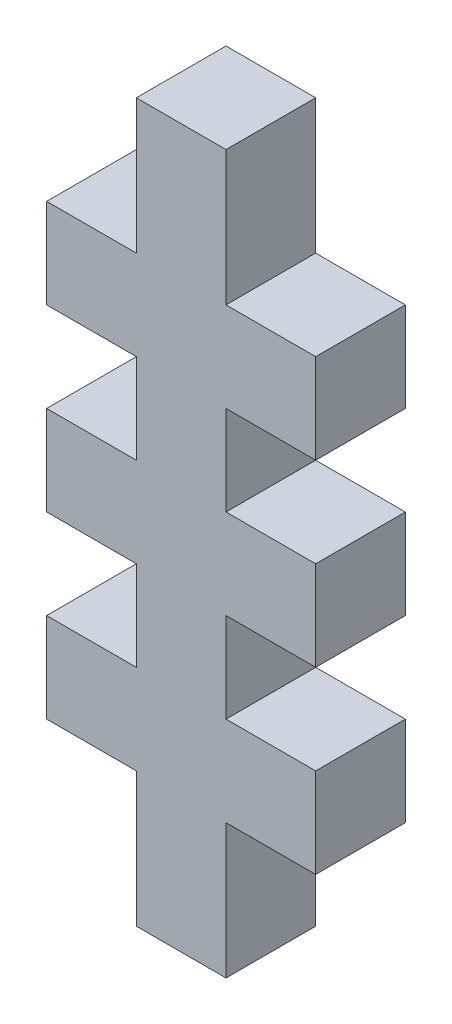
from build123d import *

# Parameters (mm, degrees)
ESQUISSE6_W               = 15
ESQUISSE6_H               = 40
BOSS_EXTRU_3_DEPTH        = 5
ESQUISSE7_W               = 5
ESQUISSE7_H               = 7.5
ENL_V_MAT_EXTRU_4_DEPTH   = 5
SYM_TRIE4_COPY_1_SKETCH_W = 5
SYM_TRIE4_COPY_1_SKETCH_H = 7.5
SYM_TRIE4_COPY_1_DEPTH    = 5
ESQUISSE9_W               = 5
ESQUISSE9_H               = 5
ENL_V_MAT_EXTRU_6_DEPTH   = 5
SYM_TRIE6_COPY_1_SKETCH_W = 5
SYM_TRIE6_COPY_1_SKETCH_H = 5
SYM_TRIE6_COPY_1_DEPTH    = 5


with BuildPart() as part:
    # Esquisse6 → Boss.-Extru.3 (new body)
    with BuildSketch(Plane.XY):
        Rectangle(ESQUISSE6_W, ESQUISSE6_H)
    extrude(amount=BOSS_EXTRU_3_DEPTH)

    # Esquisse7 → Enlèv. mat.-Extru.4 (cut)
    with BuildSketch(Plane.XY):
        with Locations((-5, 16.25)):
            Rectangle(ESQUISSE7_W, ESQUISSE7_H)
    enl_v_mat_extru_4 = extrude(amount=ENL_V_MAT_EXTRU_4_DEPTH, mode=Mode.SUBTRACT)

    # Symétrie3: Enlèv. mat.-Extru.4 across plane
    add(enl_v_mat_extru_4.mirror(Plane.ZX), mode=Mode.SUBTRACT)

    # Symétrie4: Enlèv. mat.-Extru.4 across plane
    add(enl_v_mat_extru_4.mirror(Plane(origin=(0, 0, 0), x_dir=(0, 0, 1), z_dir=(1, 0, 0))), mode=Mode.SUBTRACT)

    # Symétrie4 copy 1 sketch → Symétrie4 copy 1 (cut)
    with BuildSketch(Plane(origin=(0, 0, 0), x_dir=(-1, 0, 0), z_dir=(0, 0, 1))):
        with Locations((-5, 16.25)):
            Rectangle(SYM_TRIE4_COPY_1_SKETCH_W, SYM_TRIE4_COPY_1_SKETCH_H)
    extrude(amount=SYM_TRIE4_COPY_1_DEPTH, mode=Mode.SUBTRACT)

    # Esquisse9 → Enlèv. mat.-Extru.6 (cut)
    with BuildSketch(Plane.XY.offset(5)):
        with Locations((-5, 5)):
            Rectangle(ESQUISSE9_W, ESQUISSE9_H)
    enl_v_mat_extru_6 = extrude(amount=-ENL_V_MAT_EXTRU_6_DEPTH, mode=Mode.SUBTRACT)

    # Symétrie5: Enlèv. mat.-Extru.6 across plane
    add(enl_v_mat_extru_6.mirror(Plane.ZX), mode=Mode.SUBTRACT)

    # Symétrie6: Enlèv. mat.-Extru.6 across plane
    add(enl_v_mat_extru_6.mirror(Plane(origin=(0, 0, 0), x_dir=(0, 0, 1), z_dir=(1, 0, 0))), mode=Mode.SUBTRACT)

    # Symétrie6 copy 1 sketch → Symétrie6 copy 1 (cut)
    with BuildSketch(Plane(origin=(0, 0, 5), x_dir=(-1, 0, 0), z_dir=(0, 0, 1))):
        with Locations((-5, 5)):
            Rectangle(SYM_TRIE6_COPY_1_SKETCH_W, SYM_TRIE6_COPY_1_SKETCH_H)
    extrude(amount=-SYM_TRIE6_COPY_1_DEPTH, mode=Mode.SUBTRACT)


solid = part.part
